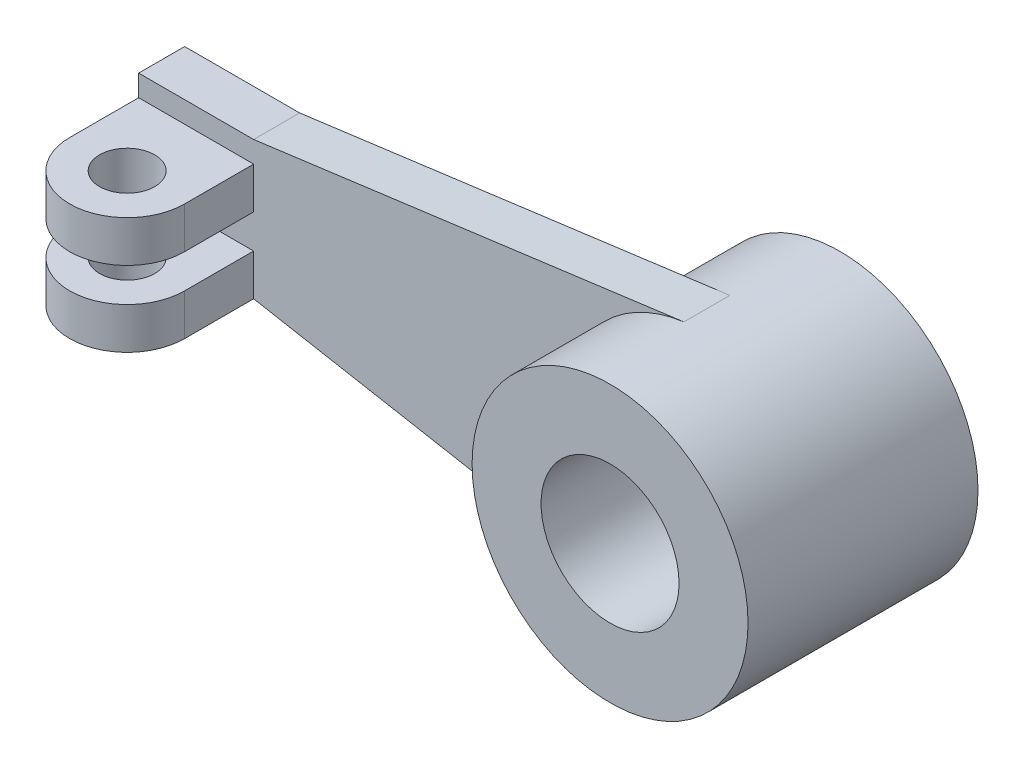
from build123d import *

# Parameters (mm, degrees)
SKETCH1_R           = 30
SKETCH1_R_2         = 15
BOSS_EXTRUDE1_DEPTH = 25
BOSS_EXTRUDE2_DEPTH = 5
SKETCH3_R           = 6
BOSS_EXTRUDE4_DEPTH = 9


with BuildPart() as part:
    # Sketch1 → Boss-Extrude1 (new body, symmetric)
    with BuildSketch(Plane.XY):
        Circle(SKETCH1_R)
        Circle(SKETCH1_R_2, mode=Mode.SUBTRACT)
    extrude(amount=BOSS_EXTRUDE1_DEPTH, both=True)

    # Sketch2 → Boss-Extrude2 (add, symmetric)
    with BuildSketch(Plane.XY):
        with BuildLine():
            Line((-3.948644693, 29.739001414), (-97.5, 17.317566762))
            Line((-97.5, 17.317566762), (-122.5, 17.317566762))
            Line((-122.5, 17.317566762), (-122.5, -12.682433238))
            Line((-122.5, -12.682433238), (-97.5, -12.682433238))
            Line((-97.5, -12.682433238), (-5.392030099, -29.511455596))
            ThreePointArc((-5.392030099, -29.511455596), (-29.99110227, 0.730605661), (-3.948644693, 29.739001414))
        make_face()
    extrude(amount=BOSS_EXTRUDE2_DEPTH, both=True)

    # Sketch3 → Boss-Extrude4 (add)
    with BuildSketch(Plane.XZ.offset(12.682433238)):
        with BuildLine():
            Line((-122.5, 5), (-97.5, 5))
            Line((-97.5, 5), (-97.5, 20))
            ThreePointArc((-97.5, 20), (-110, 32.5), (-122.5, 20))
            Line((-122.5, 20), (-122.5, 5))
        make_face()
        with Locations(Location((-110, 20, 0), (0, 0, 270))):  # turned: the seam where the file's is
            Circle(SKETCH3_R, mode=Mode.SUBTRACT)
    boss_extrude4 = extrude(amount=-BOSS_EXTRUDE4_DEPTH)

    # Mirror1: Boss-Extrude4 across plane
    add(boss_extrude4.mirror(Plane.ZX))


solid = part.part
